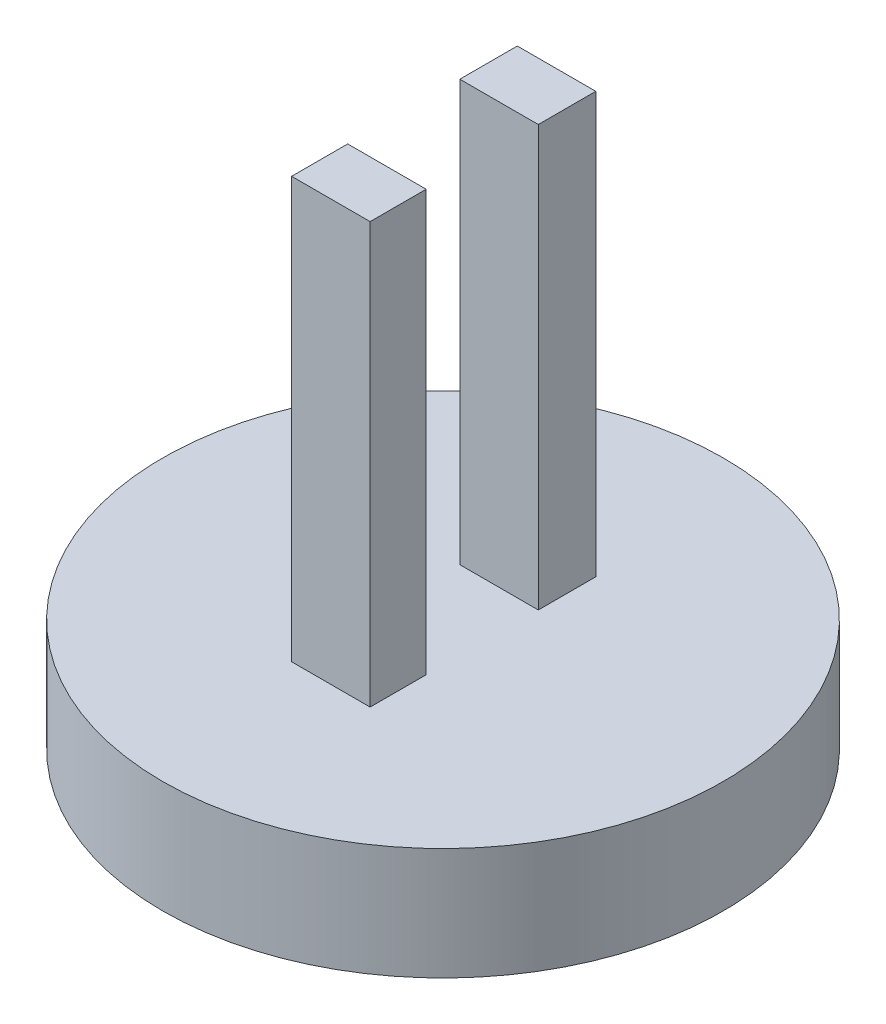
from build123d import *

# Parameters (mm, degrees)
SKETCH1_R           = 12.7
BOSS_EXTRUDE1_DEPTH = 5.08
SKETCH2_W           = 3.556
SKETCH2_H           = 2.604656918
SKETCH2_H_2         = 2.54
BOSS_EXTRUDE2_DEPTH = 19.05


with BuildPart() as part:
    # Sketch1 → Boss-Extrude1 (new body)
    with BuildSketch(Plane(origin=(0, 0, 0), x_dir=(1, 0, 0), z_dir=(0, 1, 0))):
        Circle(SKETCH1_R)
    extrude(amount=BOSS_EXTRUDE1_DEPTH)

    # Sketch2 → Boss-Extrude2 (add)
    with BuildSketch(Plane(origin=(0, 5.08, 0), x_dir=(1, 0, 0), z_dir=(0, 1, 0))):
        with Locations((0, 3.842328459)):
            Rectangle(SKETCH2_W, SKETCH2_H)
        with Locations((0, -3.81)):
            Rectangle(SKETCH2_W, SKETCH2_H_2)
    extrude(amount=BOSS_EXTRUDE2_DEPTH)


solid = part.part
